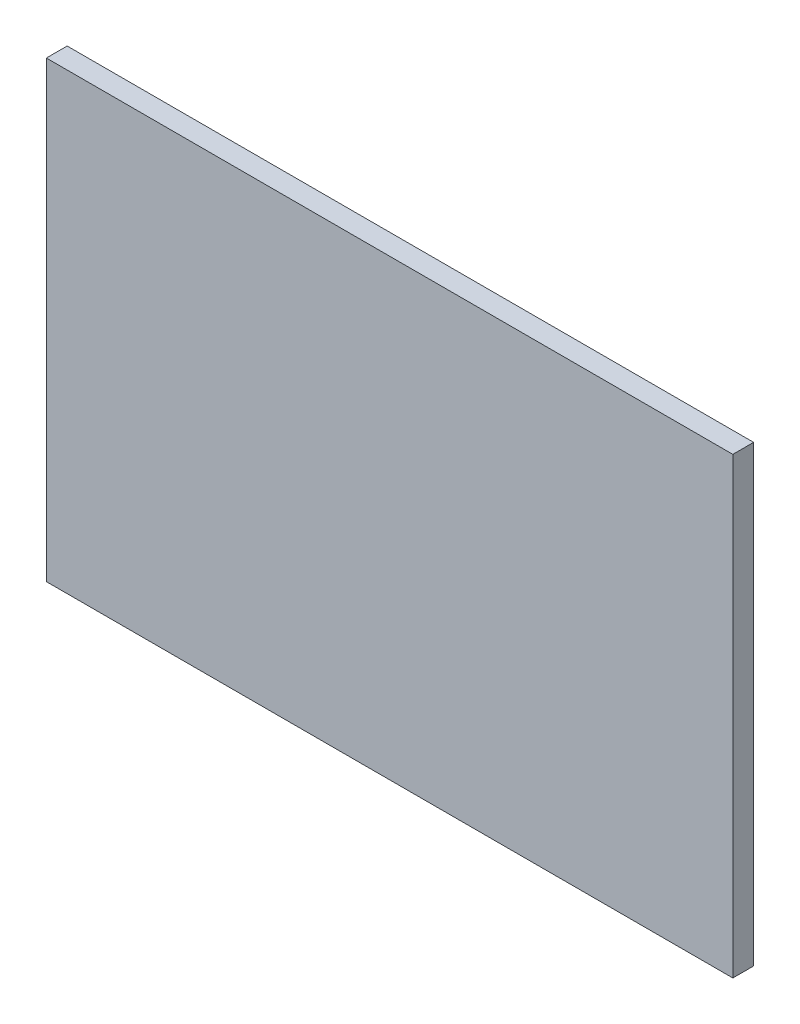
from build123d import *

# Parameters (mm, degrees)
SKETCH_1_W      = 165
SKETCH_1_H      = 109
EXTRUDE_1_DEPTH = 5


with BuildPart() as part:
    # 草图1 → 凸台-拉伸1 (new body)
    with BuildSketch(Plane.XY):
        Rectangle(SKETCH_1_W, SKETCH_1_H)
    extrude(amount=EXTRUDE_1_DEPTH)


solid = part.part
